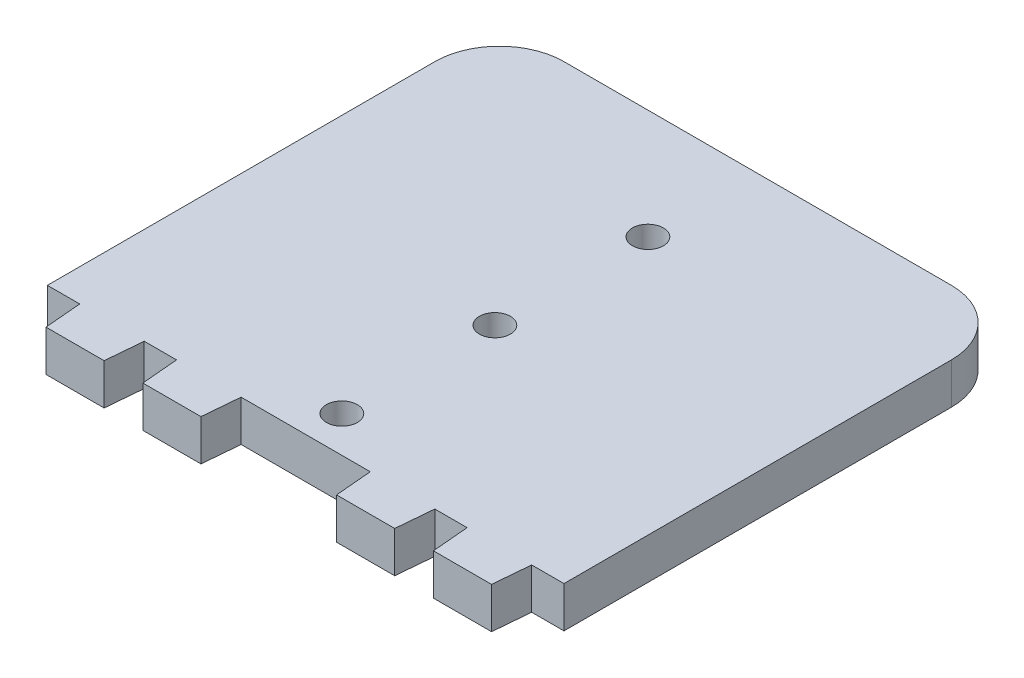
from build123d import *

# Parameters (mm, degrees)
SKETCH1_W           = 80
SKETCH1_H           = 70
SKETCH1_R           = 2.4
BOSS_EXTRUDE1_DEPTH = 6.35
FILLET1_R           = 10


with BuildPart() as part:
    # Sketch1 → Boss-Extrude1 (new body)
    with BuildSketch(Plane(origin=(0, 0, 0), x_dir=(1, 0, 0), z_dir=(0, 1, 0))):
        Rectangle(SKETCH1_W, SKETCH1_H)
        with Locations((0, 18)):
            Circle(SKETCH1_R, mode=Mode.SUBTRACT)
        with Locations((0, -5.7)):
            Circle(SKETCH1_R, mode=Mode.SUBTRACT)
        with Locations((0, -29.4)):
            Circle(SKETCH1_R, mode=Mode.SUBTRACT)
        Polygon((-20, -35), (-10, -35), (-10.5, -40.715), (-19.5, -40.715), align=None)
        Polygon((10, -35), (10.5, -40.715), (19.5, -40.715), (20, -35), align=None)
        Polygon((-35, -35), (-25, -35), (-25.5, -40.715), (-34.5, -40.715), align=None)
        Polygon((25, -35), (25.5, -40.715), (34.5, -40.715), (35, -35), align=None)
    extrude(amount=BOSS_EXTRUDE1_DEPTH)

    # Fillet1
    fillet1_edges = [part.edges().sort_by_distance(p)[0] for p in [
        (-40, 3.175, -35),
        (40, 3.175, -35),
    ]]
    fillet(fillet1_edges, radius=FILLET1_R)


solid = part.part
